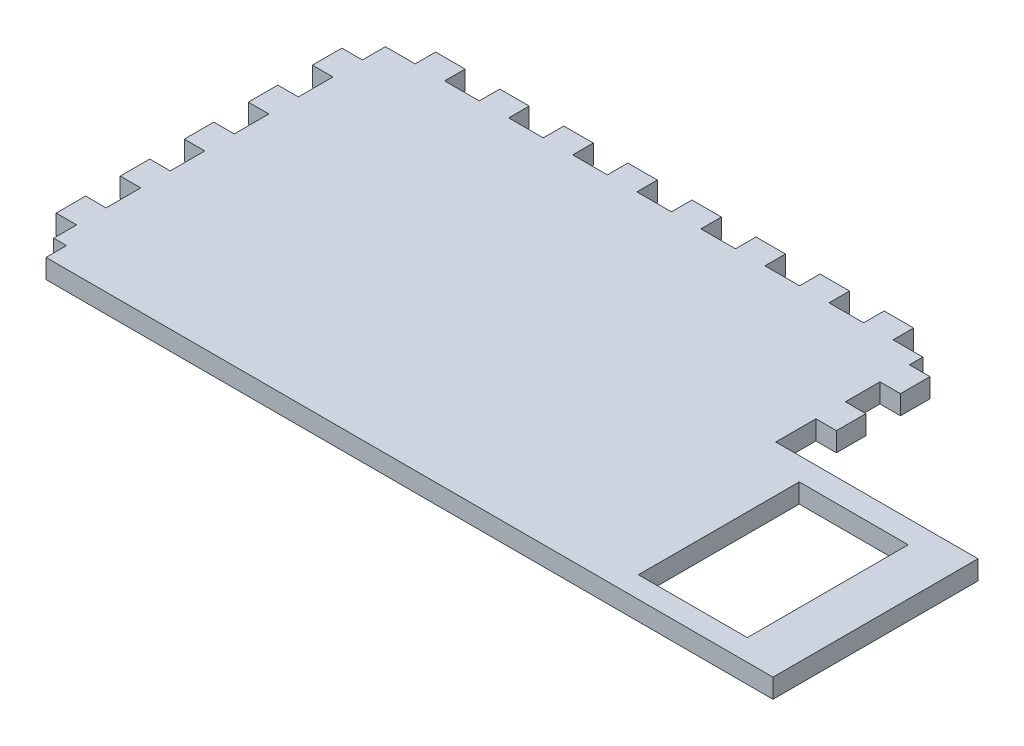
from build123d import *

# Parameters (mm, degrees)
BOSS_EXTRUDE3_DEPTH = 3
SKETCH2_W           = 17
SKETCH2_H           = 25.1
CUT_EXTRUDE1_DEPTH  = 3


with BuildPart() as part:
    # Sketch1 → Boss-Extrude3 (new body)
    with BuildSketch(Plane(origin=(0, 0, 0), x_dir=(1, 0, 0), z_dir=(0, 1, 0))):
        Polygon((-28.897216547, -2.282245917), (-28.897216547, -7.679745917), (-32.097216547, -7.679745917), (-32.097216547, -12.279745917), (-28.897216547, -12.279745917), (-28.897216547, -15.869745917), (-26.897216547, -15.869745917), (-26.897216547, -19.069745917), (55.002783453, -19.069745917), (86.572783453, -19.069745917), (86.572783453, 12.930254083), (55.002783453, 12.930254083), (55.002783453, 19.200254083), (58.202783453, 19.200254083), (58.202783453, 23.800254083), (55.002783453, 23.800254083), (55.002783453, 29.200254083), (58.202783453, 29.200254083), (58.202783453, 33.800254083), (55.002783453, 33.800254083), (55.002783453, 35.900254083), (50.352783453, 35.900254083), (50.352783453, 39.100254083), (45.752783453, 39.100254083), (45.752783453, 35.900254083), (40.352783453, 35.900254083), (40.352783453, 39.100254083), (35.752783453, 39.100254083), (35.752783453, 35.900254083), (30.352783453, 35.900254083), (30.352783453, 39.100254083), (25.752783453, 39.100254083), (25.752783453, 35.900254083), (20.352783453, 35.900254083), (20.352783453, 39.100254083), (15.752783453, 39.100254083), (15.752783453, 35.900254083), (10.352783453, 35.900254083), (10.352783453, 39.100254083), (5.752783453, 39.100254083), (5.752783453, 35.900254083), (0.352783453, 35.900254083), (0.352783453, 39.100254083), (-4.247216547, 39.100254083), (-4.247216547, 35.900254083), (-9.647216547, 35.900254083), (-9.647216547, 39.100254083), (-14.247216547, 39.100254083), (-14.247216547, 35.900254083), (-19.647216547, 35.900254083), (-19.647216547, 39.100254083), (-24.247216547, 39.100254083), (-24.247216547, 35.900254083), (-28.897216547, 35.900254083), (-28.897216547, 32.310254083), (-32.097216547, 32.310254083), (-32.097216547, 27.710254083), (-28.897216547, 27.710254083), (-28.897216547, 22.312754083), (-32.097216547, 22.312754083), (-32.097216547, 17.712754083), (-28.897216547, 17.712754083), (-28.897216547, 12.315254083), (-32.097216547, 12.315254083), (-32.097216547, 7.715254083), (-28.897216547, 7.715254083), (-28.897216547, 2.317754083), (-32.097216547, 2.317754083), (-32.097216547, -2.282245917), align=None)
    extrude(amount=BOSS_EXTRUDE3_DEPTH)

    # Sketch2 → Cut-Extrude1 (cut)
    with BuildSketch(Plane(origin=(0, 3, 0), x_dir=(1, 0, 0), z_dir=(0, 1, 0))):
        with Locations((70.732783453, -3.179745917)):
            Rectangle(SKETCH2_W, SKETCH2_H)
    extrude(amount=-CUT_EXTRUDE1_DEPTH, mode=Mode.SUBTRACT)


solid = part.part
